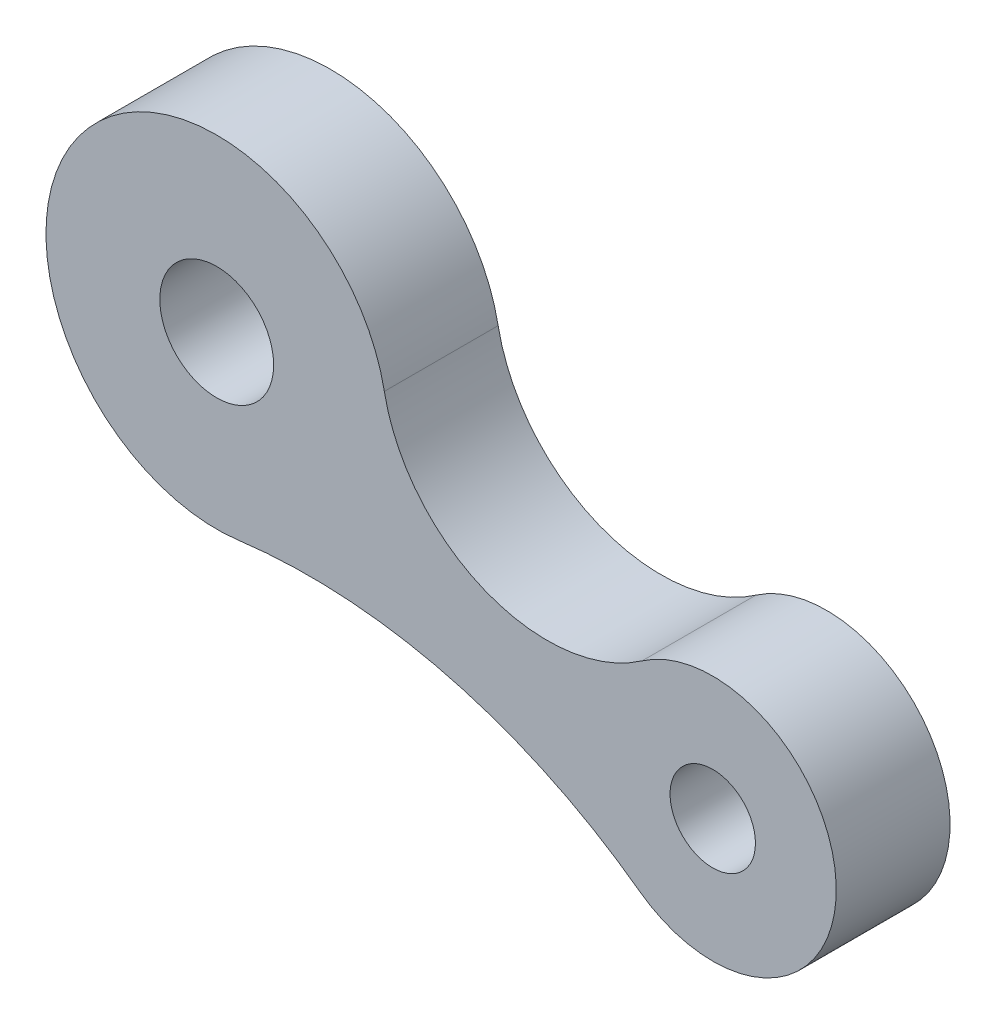
from build123d import *

# Parameters (mm, degrees)
SKETCH_1_R      = 20
SKETCH_1_R_2    = 15
EXTRUDE_1_DEPTH = 40


with BuildPart() as part:
    # 草图1 → 凸台-拉伸1 (new body)
    with BuildSketch(Plane.XY):
        with BuildLine():
            ThreePointArc((27.429809999, 11.422478676), (-80.102964492, 35.144202339), (-23.833167055, -59.51163562))
            ThreePointArc((-23.833167055, -59.51163562), (50.170086992, -64.137466239), (117.171973657, -95.89635636))
            ThreePointArc((117.171973657, -95.89635636), (186.23358476, -61.414121354), (118.011570955, -25.299200732))
            ThreePointArc((118.011570955, -25.299200732), (62.760319476, -31.507715142), (27.429809999, 11.422478676))
        make_face()
        with Locations((-31.472880779, 0)):
            Circle(SKETCH_1_R, mode=Mode.SUBTRACT)
        with Locations((142.83665365, -60.898010673)):
            Circle(SKETCH_1_R_2, mode=Mode.SUBTRACT)
    extrude(amount=EXTRUDE_1_DEPTH)


solid = part.part
